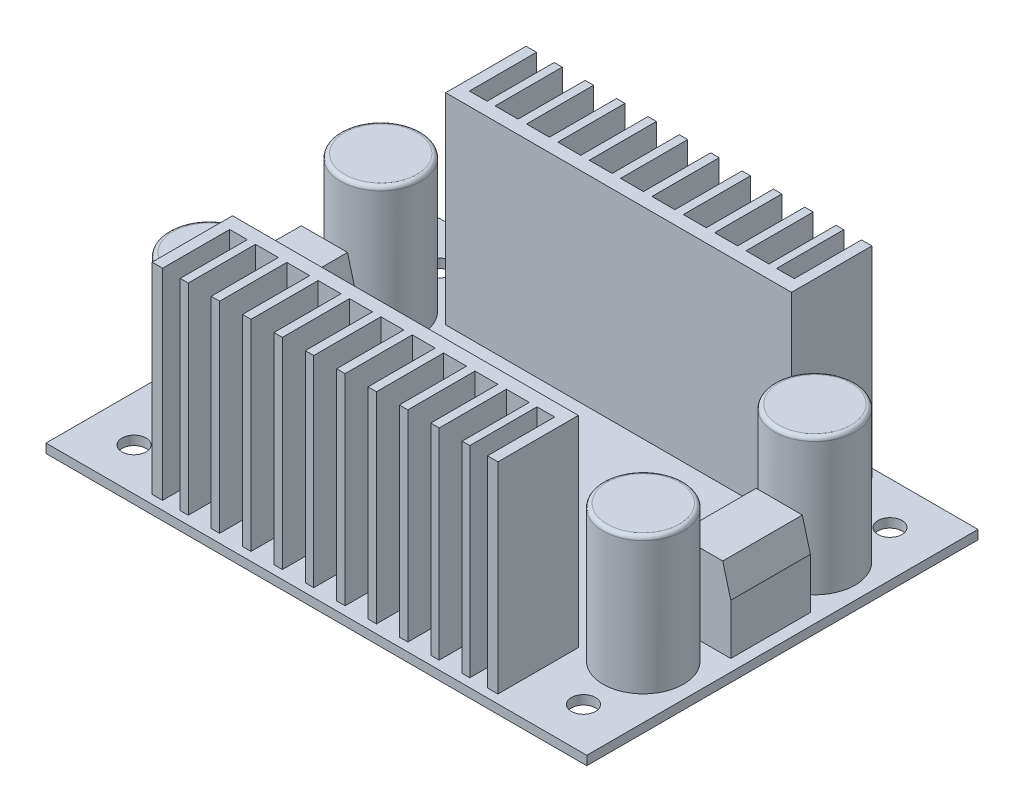
from build123d import *

# Parameters (mm, degrees)
SKETCH1_W                 = 67.2338
SKETCH1_H                 = 48.641
BOSS_EXTRUDE1_DEPTH       = 1.1303
F_3_0MM_DOWEL_HOLE1_D     = 3
SKETCH5_R                 = 5
BOSS_EXTRUDE2_DEPTH       = 17
FILLET1_R                 = 0.5
SKETCH6_W                 = 43
SKETCH6_H                 = 10
BOSS_EXTRUDE3_DEPTH       = 25
SKETCH7_W                 = 2.2
SKETCH7_H                 = 8.35
SKETCH7_W_2               = 2.85
CUT_EXTRUDE1_DEPTH        = 25
SKETCH8_W                 = 7.75
SKETCH8_H                 = 9.9
BOSS_EXTRUDE4_DEPTH       = 10
CHAMFER1_SIZE             = 1
CHAMFER1_SIZE2            = 3.732050808
CHAMFER1_OF_MIRROR2_SIZE2 = 1
CHAMFER1_OF_MIRROR2_SIZE  = 3.732050808


with BuildPart() as part:
    # Sketch1 → Boss-Extrude1 (new body)
    with BuildSketch(Plane(origin=(0, 0, 0), x_dir=(1, 0, 0), z_dir=(0, 1, 0))):
        Rectangle(SKETCH1_W, SKETCH1_H)
    extrude(amount=BOSS_EXTRUDE1_DEPTH)

    # Ø3.0mm Dowel Hole1 (through all)
    with Locations(Plane(origin=(0, 1.1303, 0), x_dir=(1, 0, 0), z_dir=(0, 1, 0))):
        with Locations((-27.94, -19.05), (-27.94, 19.05), (27.94, 19.05), (27.94, -19.05)):
            Hole(F_3_0MM_DOWEL_HOLE1_D / 2)

    # Sketch5 → Boss-Extrude2 (add)
    with BuildSketch(Plane(origin=(0, 1.1303, 0), x_dir=(1, 0, 0), z_dir=(0, 1, 0))):
        with Locations((-26.9875, 10.668)):
            Circle(SKETCH5_R)
        with Locations((-26.9875, -10.668)):
            Circle(SKETCH5_R)
        with Locations((26.9875, 10.668)):
            Circle(SKETCH5_R)
        with Locations((26.9875, -10.668)):
            Circle(SKETCH5_R)
    extrude(amount=BOSS_EXTRUDE2_DEPTH)

    # Fillet1
    fillet1_edges = [part.edges().sort_by_distance(p)[0] for p in [
        (-31.9875, 18.1303, -10.668),
        (-31.9875, 18.1303, 10.668),
        (21.9875, 18.1303, -10.668),
        (21.9875, 18.1303, 10.668),
    ]]
    fillet(fillet1_edges, radius=FILLET1_R)

    # Sketch6 → Boss-Extrude3 (add)
    with BuildSketch(Plane(origin=(0, 1.1303, 0), x_dir=(1, 0, 0), z_dir=(0, 1, 0))):
        with Locations((0, 18.25)):
            Rectangle(SKETCH6_W, SKETCH6_H)
    boss_extrude3 = extrude(amount=BOSS_EXTRUDE3_DEPTH)

    # Sketch7 → Cut-Extrude1 (cut)
    with BuildSketch(Plane(origin=(0, 26.1303, 0), x_dir=(1, 0, 0), z_dir=(0, 1, 0))):
        with Locations((-19.1, 19.075)):
            Rectangle(SKETCH7_W, SKETCH7_H)
        with Locations((-15.575, 19.075)):
            Rectangle(SKETCH7_W_2, SKETCH7_H)
        with Locations((19.1, 19.075)):
            Rectangle(SKETCH7_W, SKETCH7_H)
        with Locations((-11.675, 19.075)):
            Rectangle(SKETCH7_W_2, SKETCH7_H)
        with Locations((-7.775, 19.075)):
            Rectangle(SKETCH7_W_2, SKETCH7_H)
        with Locations((-3.875, 19.075)):
            Rectangle(SKETCH7_W_2, SKETCH7_H)
        with Locations((0.025, 19.075)):
            Rectangle(SKETCH7_W_2, SKETCH7_H)
        with Locations((3.925, 19.075)):
            Rectangle(SKETCH7_W_2, SKETCH7_H)
        with Locations((7.825, 19.075)):
            Rectangle(SKETCH7_W_2, SKETCH7_H)
        with Locations((11.725, 19.075)):
            Rectangle(SKETCH7_W_2, SKETCH7_H)
        with Locations((15.625, 19.075)):
            Rectangle(SKETCH7_W_2, SKETCH7_H)
    cut_extrude1 = extrude(amount=-CUT_EXTRUDE1_DEPTH, mode=Mode.SUBTRACT)

    # Mirror1: Boss-Extrude3, Cut-Extrude1 across plane
    add(boss_extrude3.mirror(Plane.XY))
    add(cut_extrude1.mirror(Plane.XY), mode=Mode.SUBTRACT)

    # Sketch8 → Boss-Extrude4 (add)
    with BuildSketch(Plane(origin=(0, 1.1303, 0), x_dir=(1, 0, 0), z_dir=(0, 1, 0))):
        with Locations((28.275, 0)):
            Rectangle(SKETCH8_W, SKETCH8_H)
    boss_extrude4 = extrude(amount=BOSS_EXTRUDE4_DEPTH)

    # Chamfer1
    chamfer1_edges = [part.edges().sort_by_distance(p)[0] for p in [
        (24.4, 11.1303, 0),
        (32.15, 11.1303, 0),
    ]]
    chamfer1_side = [part.faces().sort_by_distance(p)[0] for p in [
        (28.275, 11.1303, 0),
    ]]
    chamfer(chamfer1_edges, length=CHAMFER1_SIZE, length2=CHAMFER1_SIZE2, reference=chamfer1_side[0])

    # Mirror2: Boss-Extrude4 across plane
    add(boss_extrude4.mirror(Plane(origin=(0, 0, 0), x_dir=(0, 0, 1), z_dir=(1, 0, 0))))

    # Chamfer1 of Mirror2
    chamfer1_of_mirror2_edges = [part.edges().sort_by_distance(p)[0] for p in [
        (-24.4, 11.1303, 0),
        (-32.15, 11.1303, 0),
    ]]
    chamfer(chamfer1_of_mirror2_edges, length=CHAMFER1_OF_MIRROR2_SIZE, length2=CHAMFER1_OF_MIRROR2_SIZE2)


solid = part.part
